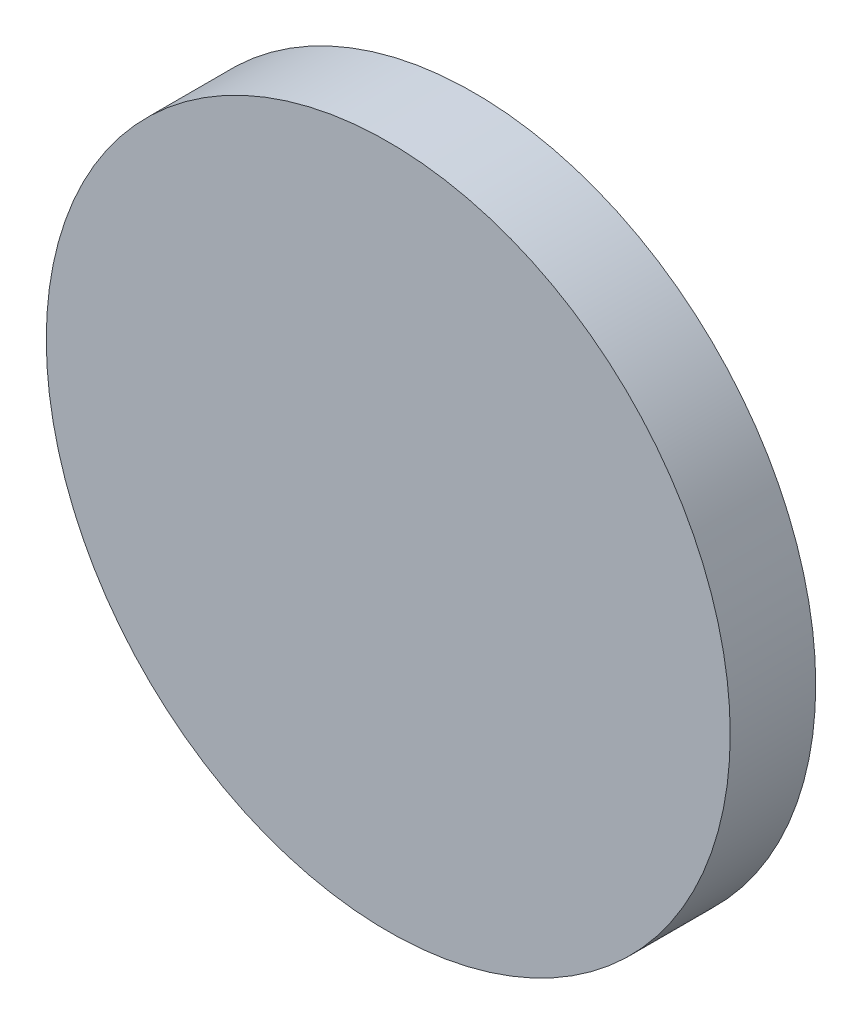
from build123d import *

# Parameters (mm, degrees)
SKETCH1_R           = 25.4
BOSS_EXTRUDE1_DEPTH = 6.35


with BuildPart() as part:
    # Sketch1 → Boss-Extrude1 (new body)
    with BuildSketch(Plane.XY):
        Circle(SKETCH1_R)
    extrude(amount=BOSS_EXTRUDE1_DEPTH)


solid = part.part
